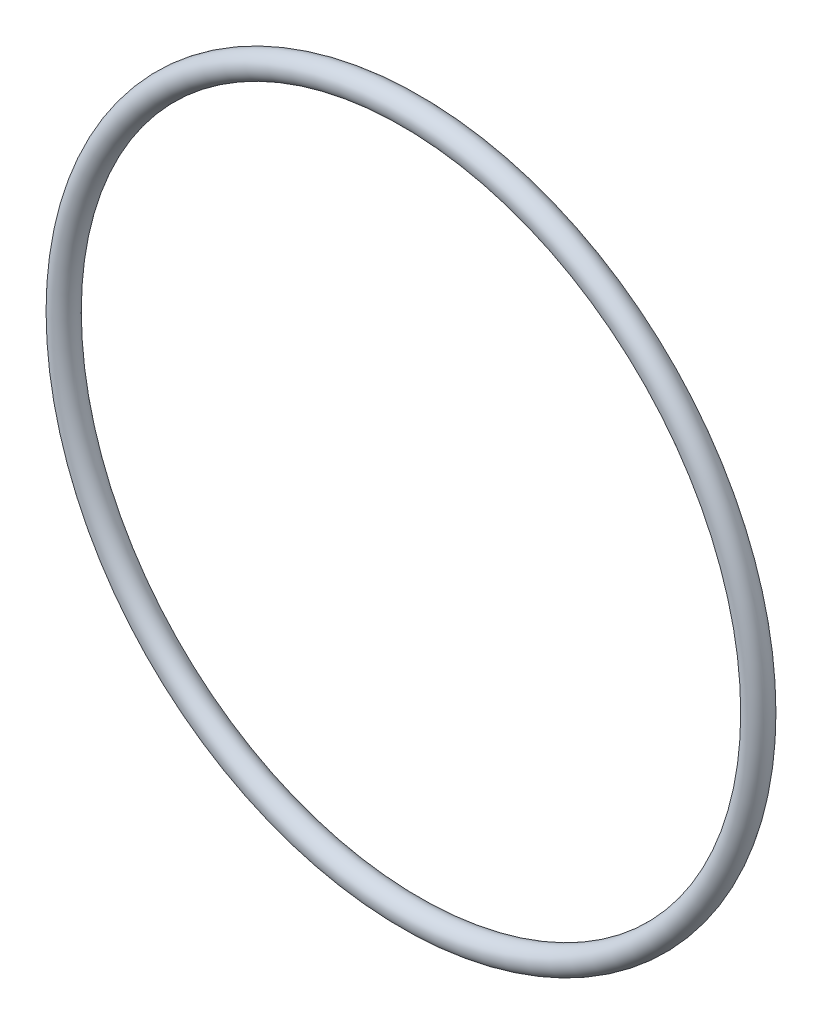
from build123d import *

# Parameters (mm, degrees)
SKETCH2_R = 1.7653


with BuildPart() as part:
    # Sketch2 → Revolve1 (revolve)
    with BuildSketch(Plane(origin=(0, 0, 0), x_dir=(1, 0, 0), z_dir=(0, 1, 0))):
        with Locations((-49.1871, 0)):
            Circle(SKETCH2_R)
    revolve(axis=Axis((0, 0, 1.7653), (0, 0, -1)))


solid = part.part
